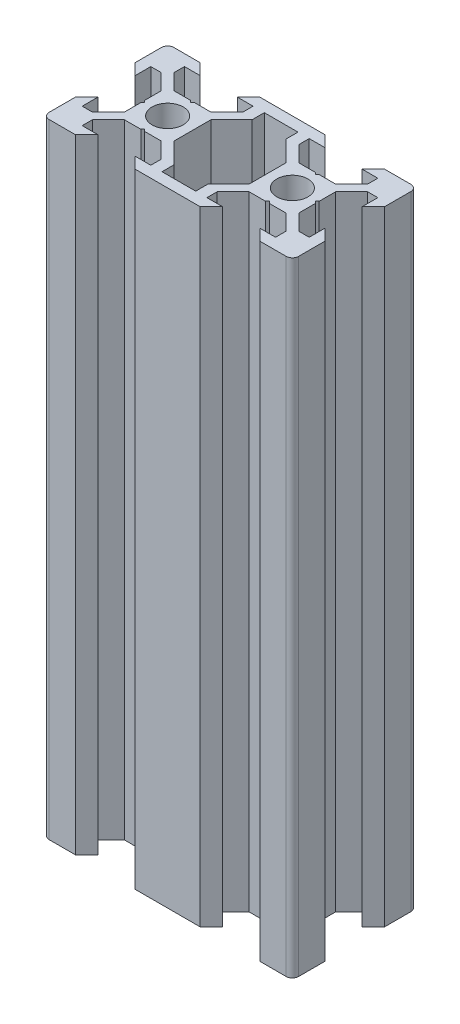
from build123d import *

# Parameters (mm, degrees)
SKETCH13_R                                  = 2.5
RETANGULAR_PF20_12_PERFIL_2040_V_SLOT_DEPTH = 100


with BuildPart() as part:
    # Sketch13 → Retangular PF20-12 - PERFIL 2040 V-SLOT(1) (new body)
    with BuildSketch(Plane(origin=(0, 0, 0), x_dir=(-1, 0, 0), z_dir=(0, 1, 0))):
        with BuildLine():
            Line((-14.8, 10), (-13, 8.2))
            Line((-13, 8.2), (-15.5, 8.2))
            Line((-15.5, 8.2), (-15.5, 6.560660172))
            Line((-15.5, 6.560660172), (-12.939339828, 4))
            Line((-12.939339828, 4), (-10.3, 4))
            Line((-10.3, 4), (-10, 3.7))
            Line((-10, 3.7), (-9.7, 4))
            Line((-9.7, 4), (-7.060660172, 4))
            Line((-7.060660172, 4), (-4.5, 6.560660172))
            Line((-4.5, 6.560660172), (-4.5, 8.2))
            Line((-4.5, 8.2), (-7, 8.2))
            Line((-7, 8.2), (-5.2, 10))
            Line((-5.2, 10), (5.2, 10))
            Line((5.2, 10), (7, 8.2))
            Line((7, 8.2), (4.5, 8.2))
            Line((4.5, 8.2), (4.5, 6.560660172))
            Line((4.5, 6.560660172), (7.060660172, 4))
            Line((7.060660172, 4), (9.7, 4))
            Line((9.7, 4), (10, 3.7))
            Line((10, 3.7), (10.3, 4))
            Line((10.3, 4), (12.939339828, 4))
            Line((12.939339828, 4), (15.5, 6.560660172))
            Line((15.5, 6.560660172), (15.5, 8.2))
            Line((15.5, 8.2), (13, 8.2))
            Line((13, 8.2), (14.8, 10))
            Line((14.8, 10), (19, 10))
            ThreePointArc((19, 10), (19.707106781, 9.707106781), (20, 9))
            Line((20, 9), (20, 4.8))
            Line((20, 4.8), (18.2, 3))
            Line((18.2, 3), (18.2, 5.5))
            Line((18.2, 5.5), (16.560660172, 5.5))
            Line((16.560660172, 5.5), (14, 2.939339828))
            Line((14, 2.939339828), (14, 0.3))
            Line((14, 0.3), (13.7, 0))
            Line((13.7, 0), (14, -0.3))
            Line((14, -0.3), (14, -2.939339828))
            Line((14, -2.939339828), (16.560660172, -5.5))
            Line((16.560660172, -5.5), (18.2, -5.5))
            Line((18.2, -5.5), (18.2, -3))
            Line((18.2, -3), (20, -4.8))
            Line((20, -4.8), (20, -9))
            ThreePointArc((20, -9), (19.707106781, -9.707106781), (19, -10))
            Line((19, -10), (14.8, -10))
            Line((14.8, -10), (13, -8.2))
            Line((13, -8.2), (15.5, -8.2))
            Line((15.5, -8.2), (15.5, -6.560660172))
            Line((15.5, -6.560660172), (12.939339828, -4))
            Line((12.939339828, -4), (10.3, -4))
            Line((10.3, -4), (10, -3.7))
            Line((10, -3.7), (9.7, -4))
            Line((9.7, -4), (7.060660172, -4))
            Line((7.060660172, -4), (4.5, -6.560660172))
            Line((4.5, -6.560660172), (4.5, -8.2))
            Line((4.5, -8.2), (7, -8.2))
            Line((7, -8.2), (5.2, -10))
            Line((5.2, -10), (-5.2, -10))
            Line((-5.2, -10), (-7, -8.2))
            Line((-7, -8.2), (-4.5, -8.2))
            Line((-4.5, -8.2), (-4.5, -6.560660172))
            Line((-4.5, -6.560660172), (-7.060660172, -4))
            Line((-7.060660172, -4), (-9.7, -4))
            Line((-9.7, -4), (-10, -3.7))
            Line((-10, -3.7), (-10.3, -4))
            Line((-10.3, -4), (-12.939339828, -4))
            Line((-12.939339828, -4), (-15.5, -6.560660172))
            Line((-15.5, -6.560660172), (-15.5, -8.2))
            Line((-15.5, -8.2), (-13, -8.2))
            Line((-13, -8.2), (-14.8, -10))
            Line((-14.8, -10), (-19, -10))
            ThreePointArc((-19, -10), (-19.707106781, -9.707106781), (-20, -9))
            Line((-20, -9), (-20, -4.8))
            Line((-20, -4.8), (-18.2, -3))
            Line((-18.2, -3), (-18.2, -5.5))
            Line((-18.2, -5.5), (-16.560660172, -5.5))
            Line((-16.560660172, -5.5), (-14, -2.939339828))
            Line((-14, -2.939339828), (-14, -0.3))
            Line((-14, -0.3), (-13.7, 0))
            Line((-13.7, 0), (-14, 0.3))
            Line((-14, 0.3), (-14, 2.939339828))
            Line((-14, 2.939339828), (-16.560660172, 5.5))
            Line((-16.560660172, 5.5), (-18.2, 5.5))
            Line((-18.2, 5.5), (-18.2, 3))
            Line((-18.2, 3), (-20, 4.8))
            Line((-20, 4.8), (-20, 9))
            ThreePointArc((-20, 9), (-19.707106781, 9.707106781), (-19, 10))
            Line((-19, 10), (-14.8, 10))
        make_face()
        with Locations((-10, 0)):
            Circle(SKETCH13_R, mode=Mode.SUBTRACT)
        with Locations((10, 0)):
            Circle(SKETCH13_R, mode=Mode.SUBTRACT)
        Polygon((-2.7, 8.2), (-2.7, 6.239339828), (-6, 2.939339828), (-6, -2.939339828), (-2.7, -6.239339828), (-2.7, -8.2), (2.7, -8.2), (2.7, -6.239339828), (6, -2.939339828), (6, 2.939339828), (2.7, 6.239339828), (2.7, 8.2), align=None, mode=Mode.SUBTRACT)
    extrude(amount=RETANGULAR_PF20_12_PERFIL_2040_V_SLOT_DEPTH)


solid = part.part
